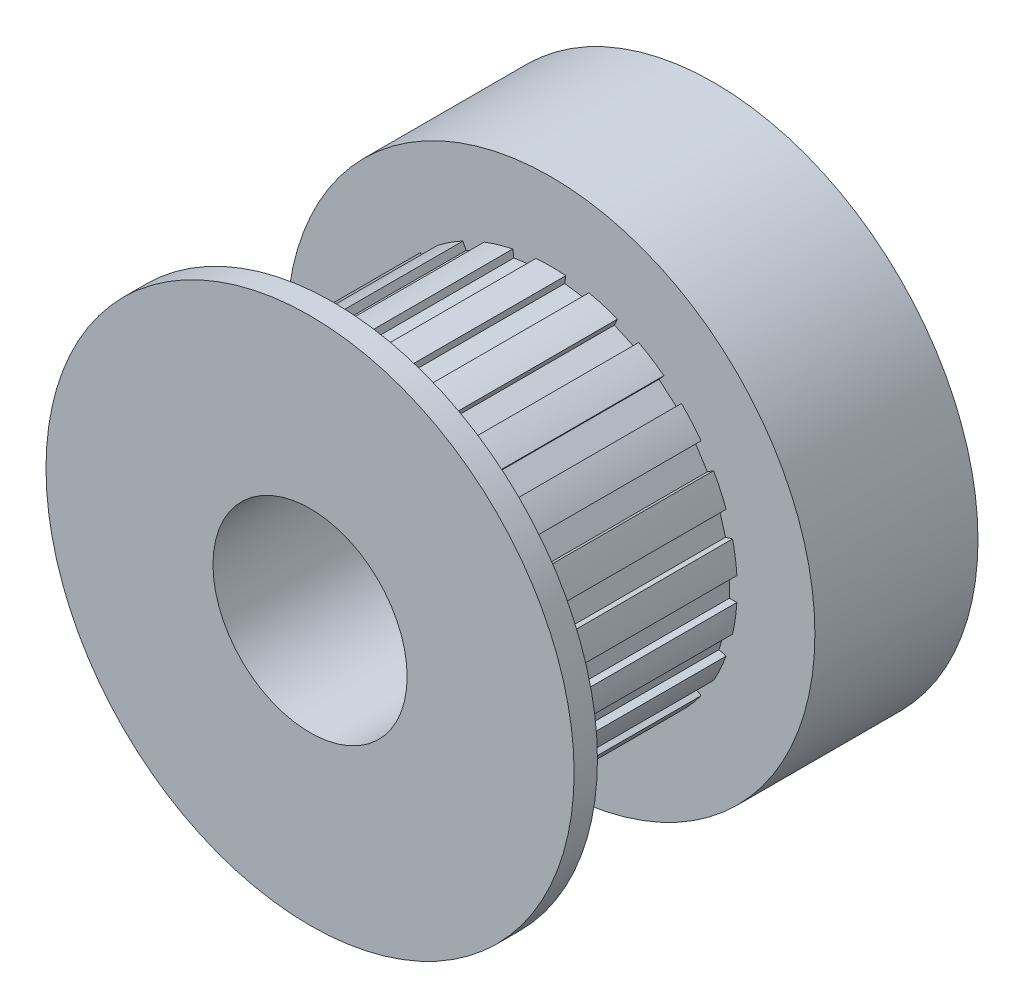
from build123d import *

# Parameters (mm, degrees)
SKETCH1_R           = 8.636
BOSS_EXTRUDE1_DEPTH = 0.762
SKETCH2_R           = 6.096
BOSS_EXTRUDE2_DEPTH = 7.112
SKETCH3_R           = 8.636
BOSS_EXTRUDE3_DEPTH = 5.334
SKETCH4_R           = 3.175
CUT_EXTRUDE1_DEPTH  = 25.654
SKETCH5_W           = 7.112
SKETCH5_H           = 0.762
CUT_EXTRUDE2_DEPTH  = 0.254
CIRPATTERN1_COUNT   = 22


with BuildPart() as part:
    # Sketch1 → Boss-Extrude1 (new body)
    with BuildSketch(Plane.XY):
        Circle(SKETCH1_R)
    extrude(amount=-BOSS_EXTRUDE1_DEPTH)

    # Sketch2 → Boss-Extrude2 (add)
    with BuildSketch(Plane(origin=(0, 0, -0.762), x_dir=(-1, 0, 0), z_dir=(0, 0, -1))):
        Circle(SKETCH2_R)
    extrude(amount=BOSS_EXTRUDE2_DEPTH)

    # Sketch3 → Boss-Extrude3 (add)
    with BuildSketch(Plane(origin=(0, 0, -7.874), x_dir=(-1, 0, 0), z_dir=(0, 0, -1))):
        Circle(SKETCH3_R)
    extrude(amount=BOSS_EXTRUDE3_DEPTH)

    # Sketch4 → Cut-Extrude1 (cut)
    with BuildSketch(Plane.XY):
        Circle(SKETCH4_R)
    extrude(amount=-CUT_EXTRUDE1_DEPTH, mode=Mode.SUBTRACT)

    # Sketch5 → Cut-Extrude2 (cut)
    with BuildSketch(Plane.ZY.offset(6.096)):
        with Locations((-4.318, 0)):
            Rectangle(SKETCH5_W, SKETCH5_H)
    cut_extrude2 = extrude(amount=-CUT_EXTRUDE2_DEPTH, mode=Mode.SUBTRACT)

    # CirPattern1: Cut-Extrude2 ×22 about axis
    cirpattern1_axis = Axis((0, 0, -13.208), (0, 0, 1))
    for i in range(1, CIRPATTERN1_COUNT):
        add(cut_extrude2.rotate(cirpattern1_axis, i * 360 / CIRPATTERN1_COUNT), mode=Mode.SUBTRACT)


solid = part.part
